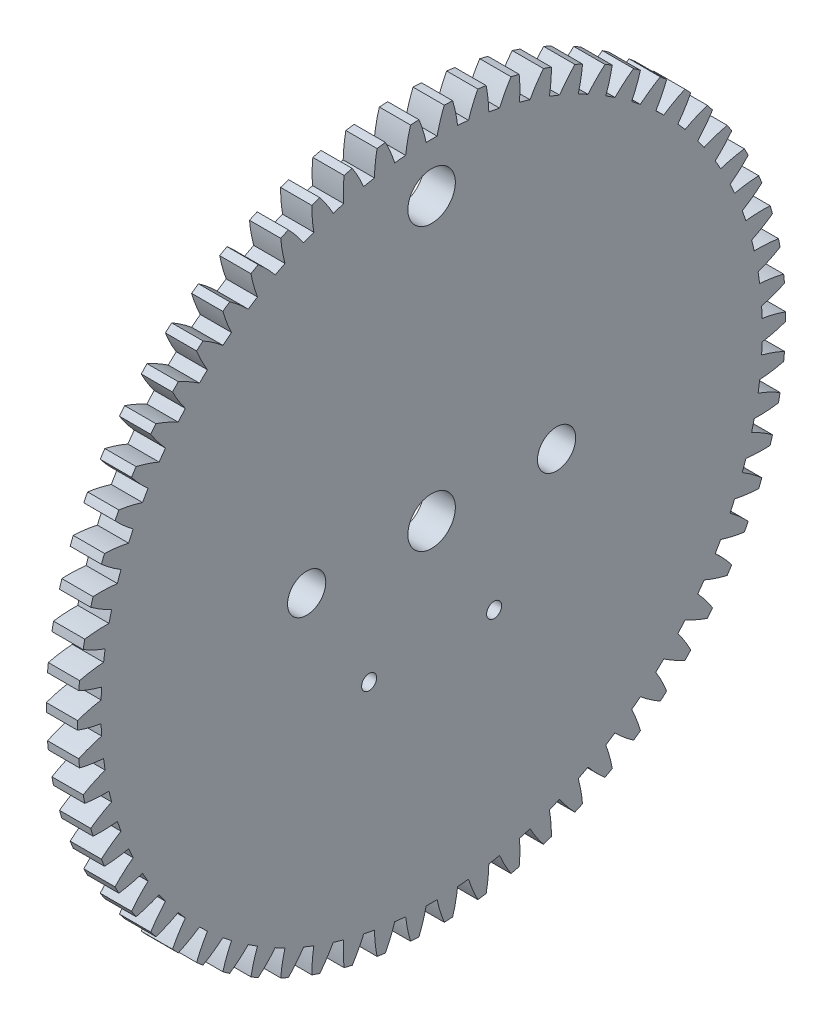
from build123d import *

# Parameters (mm, degrees)
BASPROSKE_W        = 3.175
BASPROSKE_H        = 35.983333333
TOOTHCUT_DEPTH     = 51.987068758
TEETHCUTS_COUNT    = 66
TEETHCUTS_ANGLE    = 354.545454545
CUT_EXTRUDE1_REACH = 52.971
SKETCH2_R          = 2.413
SKETCH2_R_2        = 1.9431
SKETCH2_R_3        = 0.762


with BuildPart() as part:
    # BasProSke → Base-Revolve (revolve)
    with BuildSketch(Plane(origin=(0, 0, 0), x_dir=(1, 0, 0), z_dir=(0, 1, 0)), mode=Mode.PRIVATE) as base_revolve_sk:
        with Locations((1.5875, 17.991666667)):
            Rectangle(BASPROSKE_W, BASPROSKE_H)
    revolve(base_revolve_sk.sketch.rotate(Axis((-10, 0, 0), (1, 0, 0)), 180), axis=Axis((-10, 0, 0), (1, 0, 0)))

    # TooCutSke → ToothCut (cut, through all)
    with BuildSketch(Plane(origin=(0, 0, 0), x_dir=(0, 0, -1), z_dir=(1, 0, 0))):
        with BuildLine():
            ThreePointArc((0.557236387, 33.59957954), (0, 33.6042), (-0.557236387, 33.59957954))
            ThreePointArc((-0.557236387, 33.59957954), (-0.873097361, 34.809033115), (-1.295805931, 35.985410422))
            ThreePointArc((-1.295805931, 35.985410422), (0, 36.008733333), (1.295805931, 35.985410422))
            ThreePointArc((1.295805931, 35.985410422), (0.873097361, 34.809033115), (0.557236387, 33.59957954))
        make_face()
    toothcut = extrude(amount=TOOTHCUT_DEPTH, mode=Mode.SUBTRACT)

    # TeethCuts: ToothCut ×66 about axis
    teethcuts_axis = Axis((-10, 0, 0), (1, 0, 0))
    for i in range(1, TEETHCUTS_COUNT):
        add(toothcut.rotate(teethcuts_axis, i * TEETHCUTS_ANGLE / (TEETHCUTS_COUNT - 1)), mode=Mode.SUBTRACT)

    # Sketch2 → Cut-Extrude1 (cut, up to next)
    with BuildSketch(Plane(origin=(3.175, 0, 0), x_dir=(0, 0, -1), z_dir=(1, 0, 0)), mode=Mode.PRIVATE) as cut_extrude1_sk1:
        Circle(SKETCH2_R)
    cut_extrude1_tool1 = extrude(cut_extrude1_sk1.sketch, amount=-CUT_EXTRUDE1_REACH, mode=Mode.PRIVATE) & part.part
    # Sketch2 → Cut-Extrude1 (cut, up to next)
    with BuildSketch(Plane(origin=(3.175, 0, 0), x_dir=(0, 0, -1), z_dir=(1, 0, 0)), mode=Mode.PRIVATE) as cut_extrude1_sk2:
        with Locations((0, 28.60314574)):
            Circle(SKETCH2_R)
    cut_extrude1_tool2 = extrude(cut_extrude1_sk2.sketch, amount=-CUT_EXTRUDE1_REACH, mode=Mode.PRIVATE) & part.part
    # Sketch2 → Cut-Extrude1 (cut, up to next)
    with BuildSketch(Plane(origin=(3.175, 0, 0), x_dir=(0, 0, -1), z_dir=(1, 0, 0)), mode=Mode.PRIVATE) as cut_extrude1_sk3:
        with Locations((-12.7, 0)):
            Circle(SKETCH2_R_2)
    cut_extrude1_tool3 = extrude(cut_extrude1_sk3.sketch, amount=-CUT_EXTRUDE1_REACH, mode=Mode.PRIVATE) & part.part
    # Sketch2 → Cut-Extrude1 (cut, up to next)
    with BuildSketch(Plane(origin=(3.175, 0, 0), x_dir=(0, 0, -1), z_dir=(1, 0, 0)), mode=Mode.PRIVATE) as cut_extrude1_sk4:
        with Locations((12.7, 0)):
            Circle(SKETCH2_R_2)
    cut_extrude1_tool4 = extrude(cut_extrude1_sk4.sketch, amount=-CUT_EXTRUDE1_REACH, mode=Mode.PRIVATE) & part.part
    # Sketch2 → Cut-Extrude1 (cut, up to next)
    with BuildSketch(Plane(origin=(3.175, 0, 0), x_dir=(0, 0, -1), z_dir=(1, 0, 0)), mode=Mode.PRIVATE) as cut_extrude1_sk5:
        with Locations((-6.35, -10.998522628)):
            Circle(SKETCH2_R_3)
    cut_extrude1_tool5 = extrude(cut_extrude1_sk5.sketch, amount=-CUT_EXTRUDE1_REACH, mode=Mode.PRIVATE) & part.part
    # Sketch2 → Cut-Extrude1 (cut, up to next)
    with BuildSketch(Plane(origin=(3.175, 0, 0), x_dir=(0, 0, -1), z_dir=(1, 0, 0)), mode=Mode.PRIVATE) as cut_extrude1_sk6:
        with Locations((6.35, -10.998522628)):
            Circle(SKETCH2_R_3)
    cut_extrude1_tool6 = extrude(cut_extrude1_sk6.sketch, amount=-CUT_EXTRUDE1_REACH, mode=Mode.PRIVATE) & part.part
    add(cut_extrude1_tool1.solids().sort_by_distance((3.175, 0, 0))[0], mode=Mode.SUBTRACT)
    add(cut_extrude1_tool2.solids().sort_by_distance((3.175, 28.603146, 0))[0], mode=Mode.SUBTRACT)
    add(cut_extrude1_tool3.solids().sort_by_distance((3.175, 0, 12.7))[0], mode=Mode.SUBTRACT)
    add(cut_extrude1_tool4.solids().sort_by_distance((3.175, 0, -12.7))[0], mode=Mode.SUBTRACT)
    add(cut_extrude1_tool5.solids().sort_by_distance((3.175, -10.998523, 6.35))[0], mode=Mode.SUBTRACT)
    add(cut_extrude1_tool6.solids().sort_by_distance((3.175, -10.998523, -6.35))[0], mode=Mode.SUBTRACT)


solid = part.part
